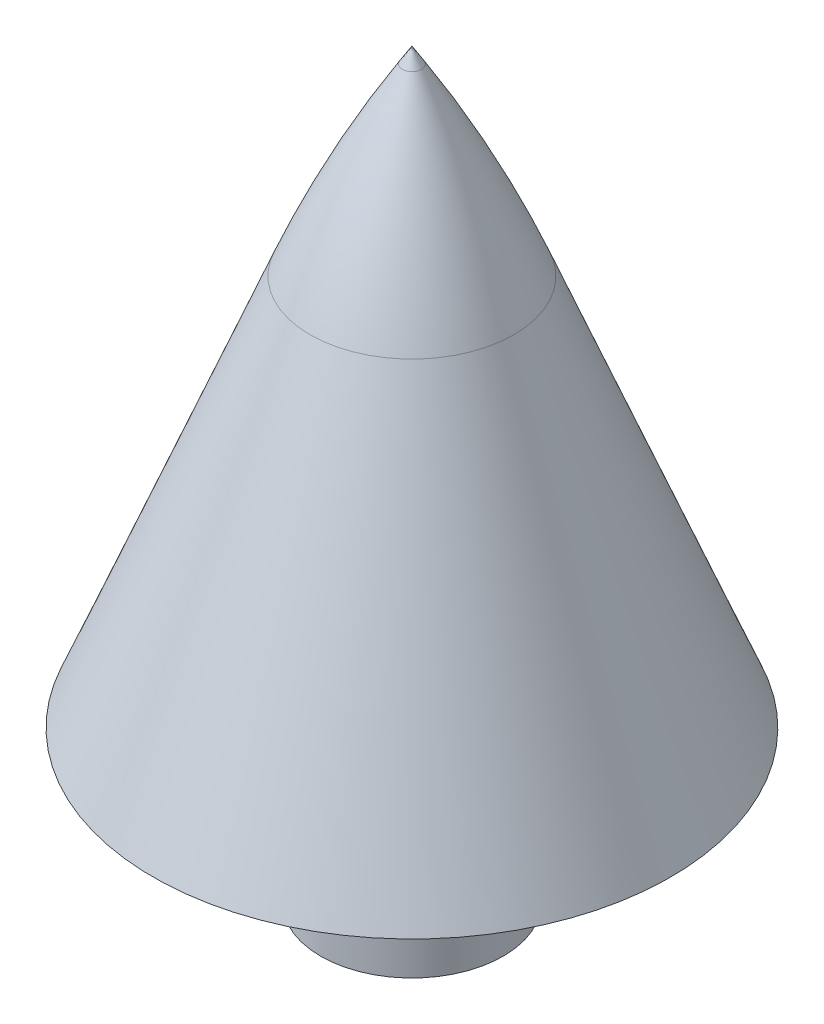
from build123d import *

# Parameters (mm, degrees)
SKETCH1_R           = 3
SKETCH1_R_2         = 1.585
BOSS_EXTRUDE1_DEPTH = 5
FILLET1_R           = 40
SKETCH8_R           = 1.585
CUT_EXTRUDE1_DEPTH  = 7


with BuildPart() as part:
    # Sketch1 → Boss-Extrude1 (new body)
    with BuildSketch(Plane(origin=(0, 0, 0), x_dir=(1, 0, 0), z_dir=(0, 1, 0))):
        Circle(SKETCH1_R)
        Circle(SKETCH1_R_2, mode=Mode.SUBTRACT)
    extrude(amount=BOSS_EXTRUDE1_DEPTH)

    # Sketch4 → Revolve6 (revolve)
    with BuildSketch(Plane.XY):
        Polygon((8.5, 5), (2.085, 21), (0, 21), (0, 5), align=None)
    revolve(axis=Axis((0, 5, 0), (0, 1, 0)))

    # Sketch7 → Revolve7 (revolve)
    with BuildSketch(Plane.XY):
        Polygon((0, 21), (2.085, 21), (0, 24.39818393), align=None)
    revolve(axis=Axis((0, 21, 0), (0, 1, 0)))

    # Fillet1
    fillet1_edges = [part.edges().sort_by_distance(p)[0] for p in [
        (-2.085, 21, 0),
    ]]
    fillet(fillet1_edges, radius=FILLET1_R)

    # Sketch8 → Cut-Extrude1 (cut)
    with BuildSketch(Plane.XZ.offset(-5)):
        Circle(SKETCH8_R)
    extrude(amount=-CUT_EXTRUDE1_DEPTH, mode=Mode.SUBTRACT)


solid = part.part
